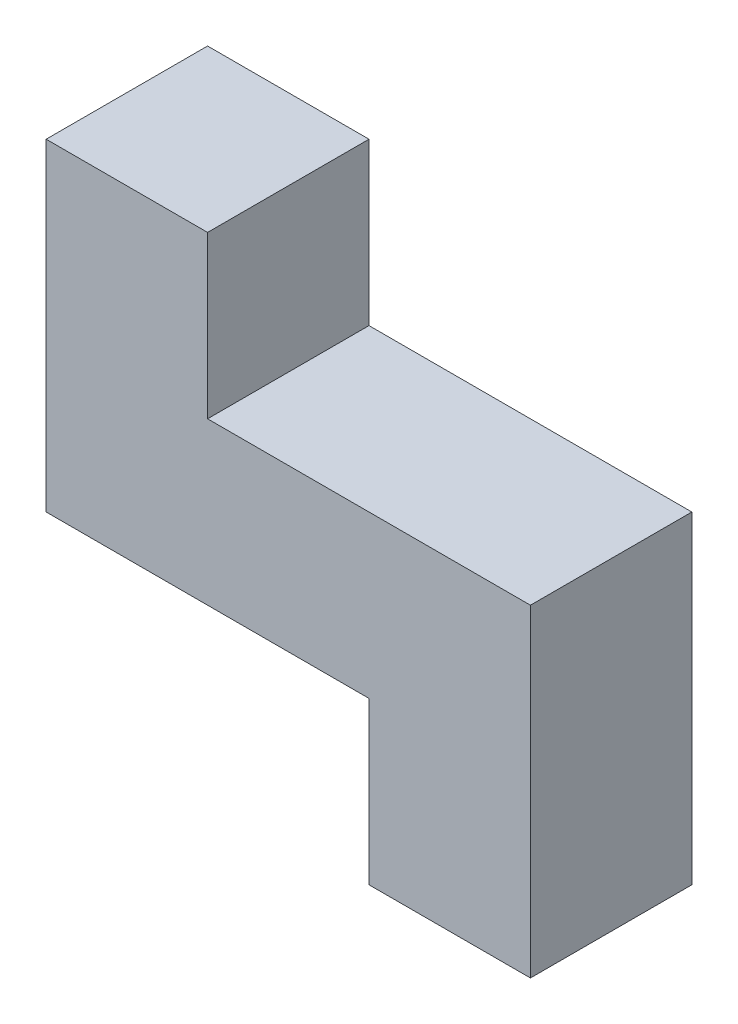
from build123d import *

# Parameters (mm, degrees)
BOSS_EXTRUDE1_DEPTH = 25.4


with BuildPart() as part:
    # Sketch1 → Boss-Extrude1 (new body)
    with BuildSketch(Plane.XY):
        Polygon((0, 76.2), (0, 25.4), (50.8, 25.4), (50.8, 0), (76.2, 0), (76.2, 50.8), (25.4, 50.8), (25.4, 76.2), align=None)
    extrude(amount=BOSS_EXTRUDE1_DEPTH)


solid = part.part
